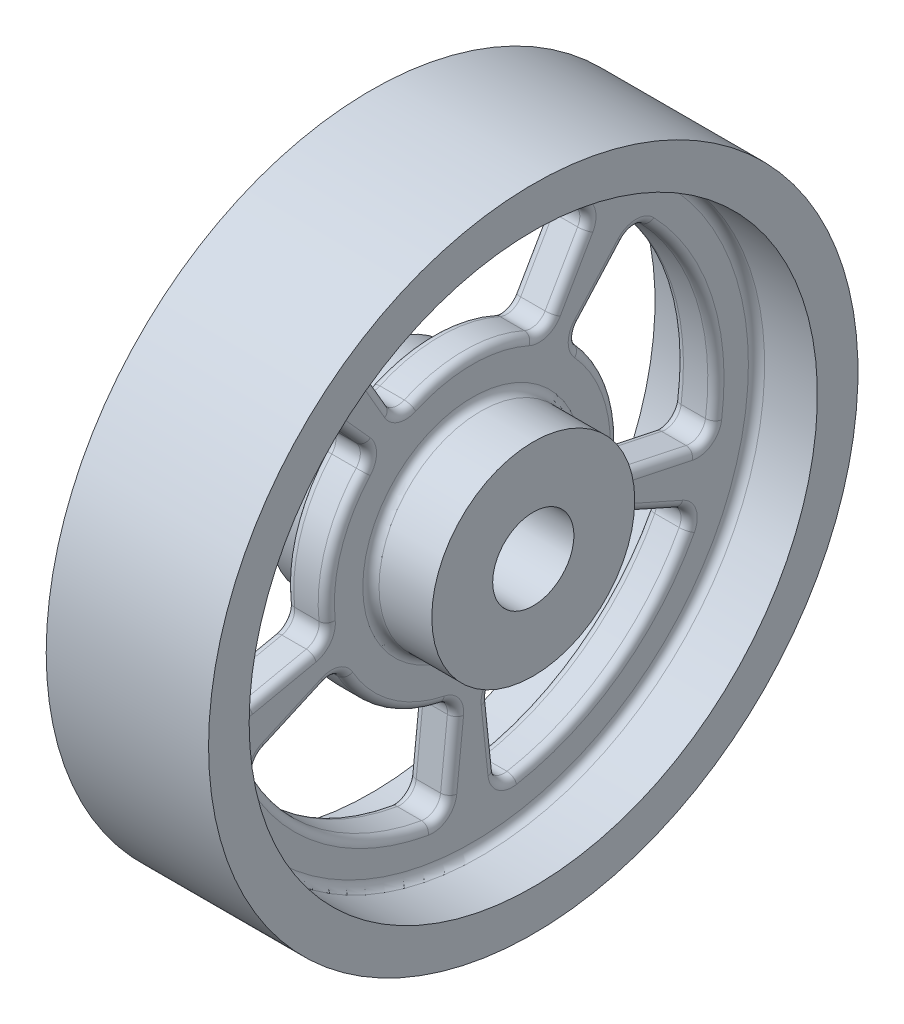
from build123d import *

# Parameters (mm, degrees)
CUT_EXTRUDE2_DEPTH       = 13.5
FILLET2_R                = 2
CIRPATTERN1_COUNT        = 5
FILLET2_OF_CIRPATTERN1_R = 2
FILLET3_R                = 1


with BuildPart() as part:
    # Sketch1 → Revolve1 (revolve)
    with BuildSketch(Plane(origin=(0, 0, 0), x_dir=(1, 0, 0), z_dir=(0, 1, 0))):
        Polygon((2.5, 35), (10, 35), (10, 40), (-10, 40), (-10, 35), (-2.5, 35), (-2.5, 12.5), (-10, 12.5), (-10, 5), (10, 5), (10, 12.5), (2.5, 12.5), align=None)
    revolve(axis=Axis((0, 0, 0), (1, 0, 0)))

    # Sketch4 → Cut-Extrude2 (cut, through all)
    with BuildSketch(Plane(origin=(2.5, 0, 0), x_dir=(0, 0, -1), z_dir=(1, 0, 0))):
        with BuildLine():
            Line((-15, 25.980762114), (-9, 15.588457268))
            ThreePointArc((-9, 15.588457268), (0, 18), (9, 15.588457268))
            Line((9, 15.588457268), (15, 25.980762114))
            ThreePointArc((15, 25.980762114), (0, 30), (-15, 25.980762114))
        make_face()
    cut_extrude2 = extrude(amount=-CUT_EXTRUDE2_DEPTH, mode=Mode.SUBTRACT)

    # Fillet2
    fillet2_edges = [part.edges().sort_by_distance(p)[0] for p in [
        (0, 15.588457268, -9),
        (0, 15.588457268, 9),
        (0, 25.980762114, 15),
        (0, 25.980762114, -15),
    ]]
    fillet(fillet2_edges, radius=FILLET2_R)

    # CirPattern1: Cut-Extrude2 ×5 about axis
    cirpattern1_axis = Axis((0, 0, 0), (1, 0, 0))
    for i in range(1, CIRPATTERN1_COUNT):
        add(cut_extrude2.rotate(cirpattern1_axis, i * 360 / CIRPATTERN1_COUNT), mode=Mode.SUBTRACT)

    # Fillet2 of CirPattern1
    fillet2_of_cirpattern1_edges = [part.edges().sort_by_distance(p)[0] for p in [
        (0, 13.376606859, 12.044350914),
        (0, -3.742410435, 17.606656813),
        (0, -6.237350725, 29.344428022),
        (0, 22.294344764, 20.073918191),
        (0, -7.321259575, 16.443818238),
        (0, -17.901394117, 1.881512339),
        (0, -29.835656861, 3.135853898),
        (0, -12.202099292, 27.406363729),
        (0, -17.901394117, -1.881512339),
        (0, -7.321259575, -16.443818238),
        (0, -12.202099292, -27.406363729),
        (0, -29.835656861, -3.135853898),
        (0, -3.742410435, -17.606656813),
        (0, 13.376606859, -12.044350914),
        (0, 22.294344764, -20.073918191),
        (0, -6.237350725, -29.344428022),
    ]]
    fillet(fillet2_of_cirpattern1_edges, radius=FILLET2_OF_CIRPATTERN1_R)

    # Fillet3
    fillet3_edges = [part.edges().sort_by_distance(p)[0] for p in [
        (2.5, 0, 35),
        (2.5, 0, 12.5),
        (-2.5, 0, 12.5),
        (-2.5, 0, 35),
        (2.5, -4.972023962, -23.391533639),
        (-2.5, -4.972023962, -23.391533639),
        (2.5, 5.562305899, -17.119017293),
        (-2.5, 5.562305899, -17.119017293),
        (2.5, 17.771650383, -16.001665879),
        (-2.5, 17.771650383, -16.001665879),
        (-2.5, 9.270509831, -28.531695489),
        (2.5, 9.270509831, -28.531695489),
        (2.5, -3.352979753, -18.260009279),
        (-2.5, -3.352979753, -18.260009279),
        (2.5, 13.445581763, -12.801825774),
        (-2.5, 13.445581763, -12.801825774),
        (2.5, -5.487704354, -28.882524769),
        (-2.5, -5.487704354, -28.882524769),
        (2.5, 21.416368191, -20.14086169),
        (-2.5, 21.416368191, -20.14086169),
        (2.5, -23.783110394, -2.49970563),
        (-2.5, -23.783110394, -2.49970563),
        (2.5, -14.562305899, -10.580134541),
        (-2.5, -14.562305899, -10.580134541),
        (2.5, -9.726746619, -21.846630597),
        (-2.5, -9.726746619, -21.846630597),
        (-2.5, -24.270509831, -17.633557569),
        (2.5, -24.270509831, -17.633557569),
        (2.5, -18.402428538, -2.453779941),
        (-2.5, -18.402428538, -2.453779941),
        (2.5, -8.020346559, -16.743489875),
        (-2.5, -8.020346559, -16.743489875),
        (2.5, -29.164707294, -3.706074009),
        (-2.5, -29.164707294, -3.706074009),
        (2.5, -12.537076026, -26.592045067),
        (-2.5, -12.537076026, -26.592045067),
        (2.5, -9.726746619, 21.846630597),
        (-2.5, -9.726746619, 21.846630597),
        (2.5, -14.562305899, 10.580134541),
        (-2.5, -14.562305899, 10.580134541),
        (2.5, -23.783110394, 2.49970563),
        (-2.5, -23.783110394, 2.49970563),
        (-2.5, -24.270509831, 17.633557569),
        (2.5, -24.270509831, 17.633557569),
        (2.5, -8.020346559, 16.743489875),
        (-2.5, -8.020346559, 16.743489875),
        (2.5, -18.402428538, 2.453779941),
        (-2.5, -18.402428538, 2.453779941),
        (2.5, -12.537076026, 26.592045067),
        (-2.5, -12.537076026, 26.592045067),
        (2.5, -29.164707294, 3.706074009),
        (-2.5, -29.164707294, 3.706074009),
        (2.5, 17.771650383, 16.001665879),
        (-2.5, 17.771650383, 16.001665879),
        (2.5, 5.562305899, 17.119017293),
        (-2.5, 5.562305899, 17.119017293),
        (2.5, -4.972023962, 23.391533639),
        (-2.5, -4.972023962, 23.391533639),
        (-2.5, 9.270509831, 28.531695489),
        (2.5, 9.270509831, 28.531695489),
        (2.5, 13.445581763, 12.801825774),
        (-2.5, 13.445581763, 12.801825774),
        (2.5, -3.352979753, 18.260009279),
        (-2.5, -3.352979753, 18.260009279),
        (2.5, 21.416368191, 20.14086169),
        (-2.5, 21.416368191, 20.14086169),
        (2.5, -5.487704354, 28.882524769),
        (-2.5, -5.487704354, 28.882524769),
        (2.5, 20.710230592, -11.957057207),
        (-2.5, 20.710230592, -11.957057207),
        (2.5, 18, 0),
        (-2.5, 18, 0),
        (2.5, 20.710230592, 11.957057207),
        (-2.5, 20.710230592, 11.957057207),
        (-2.5, 30, 0),
        (2.5, 30, 0),
        (2.5, 16.330173087, -8.831526428),
        (-2.5, 16.330173087, -8.831526428),
        (2.5, 16.330173087, 8.831526428),
        (-2.5, 16.330173087, 8.831526428),
        (2.5, 25.773119483, -14.14430798),
        (-2.5, 25.773119483, -14.14430798),
        (2.5, 25.773119483, 14.14430798),
        (-2.5, 25.773119483, 14.14430798),
    ]]
    fillet(fillet3_edges, radius=FILLET3_R)


solid = part.part
